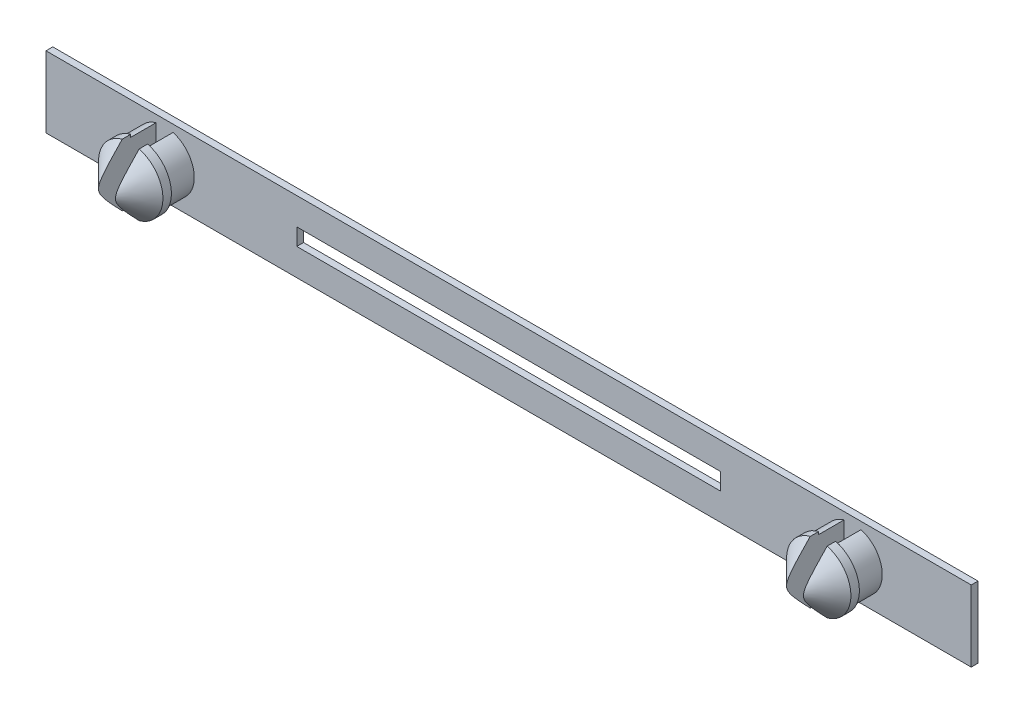
from build123d import *

# Parameters (mm, degrees)
SKICA2_W                 = 54.6
SKICA2_H                 = 4.2
SKICA2_W_2               = 25
SKICA2_H_2               = 1
P_IDAT_VYSUNUT_M2_DEPTH  = 0.4
SKICA3_R                 = 1.75
P_IDAT_VYSUNUT_M3_DEPTH  = 1.5
SKICA5_R                 = 1.9
P_IDAT_VYSUNUT_M5_DEPTH  = 2
ZKOSEN_2_SIZE            = 1.5
SKICA7_W                 = 1
SKICA7_H                 = 5
ODEBRAT_VYSUNUT_M1_DEPTH = 3.5


with BuildPart() as part:
    # Skica2 → Přidat vysunutím2 (new body)
    with BuildSketch(Plane.XY):
        Rectangle(SKICA2_W, SKICA2_H)
        Rectangle(SKICA2_W_2, SKICA2_H_2, mode=Mode.SUBTRACT)
    extrude(amount=P_IDAT_VYSUNUT_M2_DEPTH)

    # Skica3 → Přidat vysunutím3 (add)
    with BuildSketch(Plane.XY.offset(0.4)):
        with Locations((-20.3, 0)):
            Circle(SKICA3_R)
        with Locations((20.3, 0)):
            Circle(SKICA3_R)
    extrude(amount=P_IDAT_VYSUNUT_M3_DEPTH)

    # Skica5 → Přidat vysunutím5 (add)
    with BuildSketch(Plane.XY.offset(1.9)):
        with Locations((-20.3, 0)):
            Circle(SKICA5_R)
        with Locations((20.3, 0)):
            Circle(SKICA5_R)
    extrude(amount=P_IDAT_VYSUNUT_M5_DEPTH)

    # Zkosení2
    zkosen_2_edges = [part.edges().sort_by_distance(p)[0] for p in [
        (-22.2, 0, 3.9),
        (18.4, 0, 3.9),
    ]]
    chamfer(zkosen_2_edges, length=ZKOSEN_2_SIZE)

    # Skica7 → Odebrat vysunutím1 (cut)
    with BuildSketch(Plane.XY.offset(3.9)):
        with Locations((-20.3, 0)):
            Rectangle(SKICA7_W, SKICA7_H)
        with Locations((20.3, 0)):
            Rectangle(SKICA7_W, SKICA7_H)
    extrude(amount=-ODEBRAT_VYSUNUT_M1_DEPTH, mode=Mode.SUBTRACT)


solid = part.part
